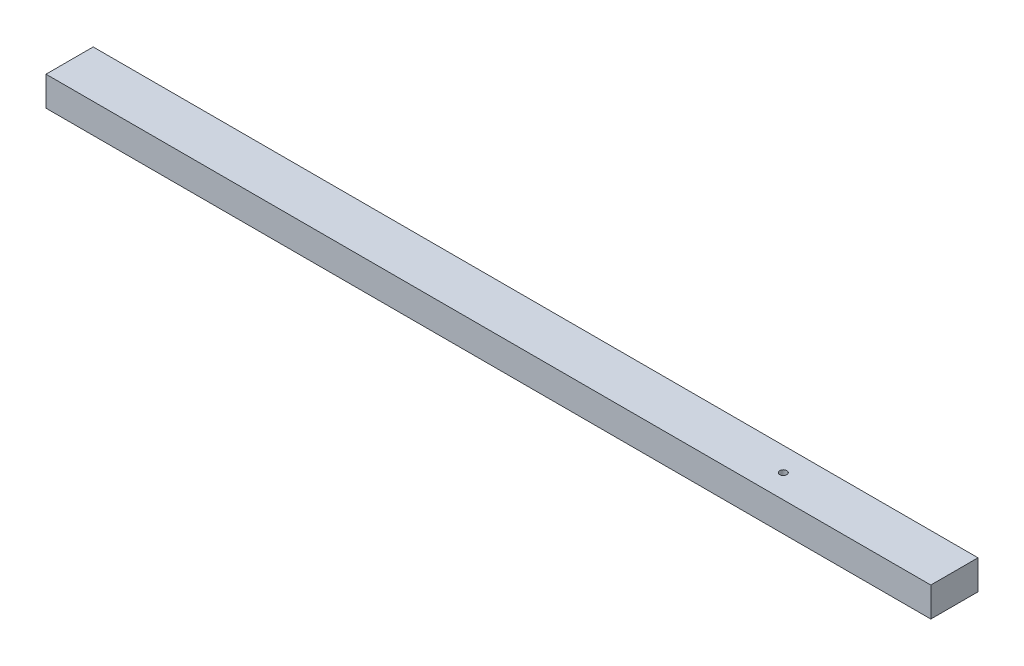
from build123d import *

# Parameters (mm, degrees)
SKETCH_1_W          = 80
SKETCH_1_H          = 50
EXTRUDE_1_DEPTH     = 1500
SKETCH_2_R          = 6
CUT_EXTRUDE_1_DEPTH = 51


with BuildPart() as part:
    # Эскиз1 → Бобышка-Вытянуть1 (new body)
    with BuildSketch(Plane(origin=(0, 0, 0), x_dir=(0, 0, -1), z_dir=(1, 0, 0))):
        with Locations((40, 25)):
            Rectangle(SKETCH_1_W, SKETCH_1_H)
    extrude(amount=EXTRUDE_1_DEPTH)

    # Эскиз2 → Вырез-Вытянуть1 (cut, through all)
    with BuildSketch(Plane(origin=(0, 50, 0), x_dir=(1, 0, 0), z_dir=(0, 1, 0))):
        with Locations((1210, 40)):
            Circle(SKETCH_2_R)
    extrude(amount=-CUT_EXTRUDE_1_DEPTH, mode=Mode.SUBTRACT)


solid = part.part
